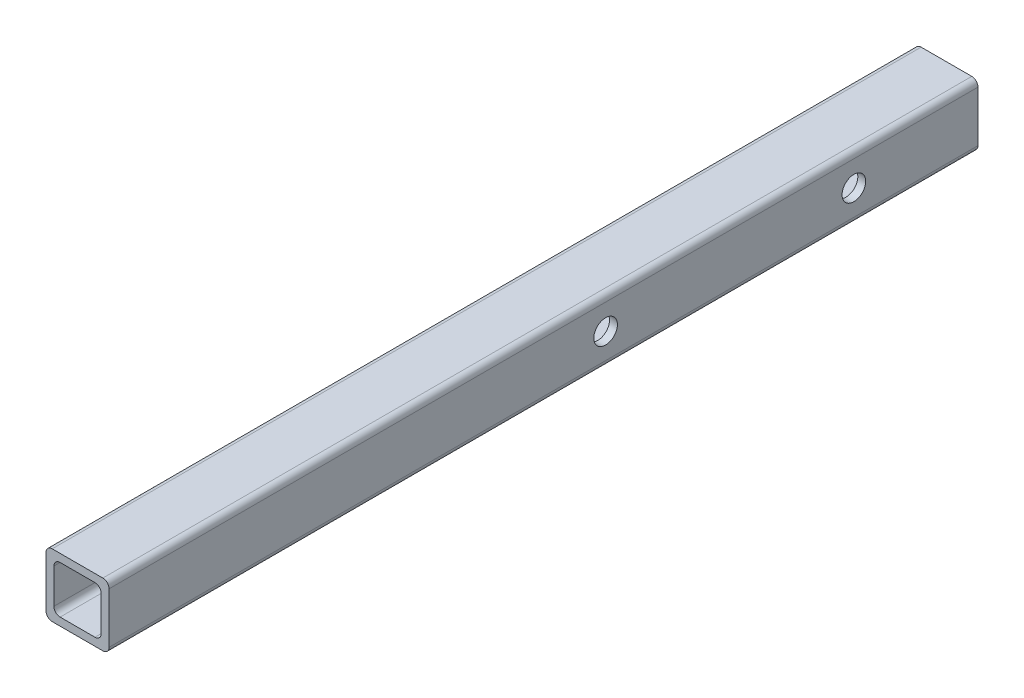
from build123d import *

# Parameters (mm, degrees)
SALIENTE_EXTRUIR1_DEPTH = 350
CROQUIS2_R              = 4.7625
CORTAR_EXTRUIR1_DEPTH   = 26.4


with BuildPart() as part:
    # Croquis1 → Saliente-Extruir1 (new body)
    with BuildSketch(Plane.XY):
        with BuildLine():
            Line((-10.2, -12.7), (10.2, -12.7))
            ThreePointArc((10.2, -12.7), (11.967766953, -11.967766953), (12.7, -10.2))
            Line((12.7, -10.2), (12.7, 10.2))
            ThreePointArc((12.7, 10.2), (11.967766953, 11.967766953), (10.2, 12.7))
            Line((10.2, 12.7), (-10.2, 12.7))
            ThreePointArc((-10.2, 12.7), (-11.967766953, 11.967766953), (-12.7, 10.2))
            Line((-12.7, 10.2), (-12.7, -10.2))
            ThreePointArc((-12.7, -10.2), (-11.967766953, -11.967766953), (-10.2, -12.7))
        make_face()
        with BuildLine():
            Line((-7.025, -9.525), (7.025, -9.525))
            ThreePointArc((7.025, -9.525), (8.792766953, -8.792766953), (9.525, -7.025))
            Line((9.525, -7.025), (9.525, 7.025))
            ThreePointArc((9.525, 7.025), (8.792766953, 8.792766953), (7.025, 9.525))
            Line((7.025, 9.525), (-7.025, 9.525))
            ThreePointArc((-7.025, 9.525), (-8.792766953, 8.792766953), (-9.525, 7.025))
            Line((-9.525, 7.025), (-9.525, -7.025))
            ThreePointArc((-9.525, -7.025), (-8.792766953, -8.792766953), (-7.025, -9.525))
        make_face(mode=Mode.SUBTRACT)
    extrude(amount=SALIENTE_EXTRUIR1_DEPTH)

    # Croquis2 → Cortar-Extruir1 (cut, through all)
    with BuildSketch(Plane.ZY.offset(12.7)):
        with Locations((50, 0)):
            Circle(CROQUIS2_R)
        with Locations((150, 0)):
            Circle(CROQUIS2_R)
    extrude(amount=-CORTAR_EXTRUIR1_DEPTH, mode=Mode.SUBTRACT)


solid = part.part
